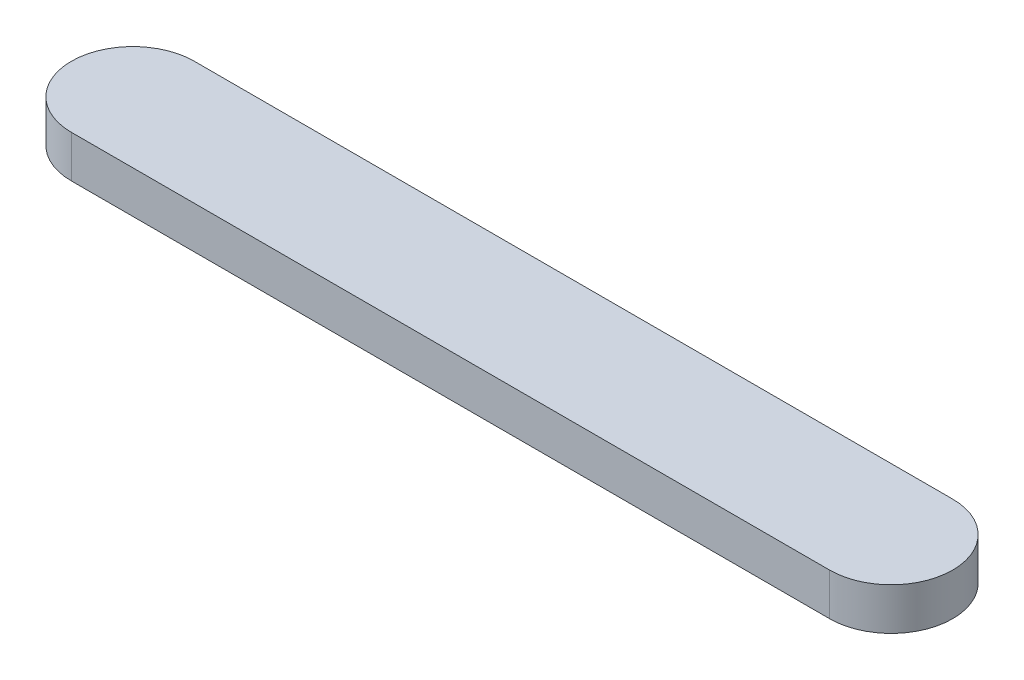
from build123d import *

# Parameters (mm, degrees)
BOSS_EXTRUDE1_DEPTH = 5


with BuildPart() as part:
    # Sketch1 → Boss-Extrude1 (new body)
    with BuildSketch(Plane(origin=(0, 0, 0), x_dir=(1, 0, 0), z_dir=(0, 1, 0))):
        with BuildLine():
            Line((0, 7.3), (90, 7.3))
            ThreePointArc((90, 7.3), (97.3, 0), (90, -7.3))
            Line((90, -7.3), (0, -7.3))
            ThreePointArc((0, -7.3), (-7.3, 0), (0, 7.3))
        make_face()
    extrude(amount=BOSS_EXTRUDE1_DEPTH)


solid = part.part
